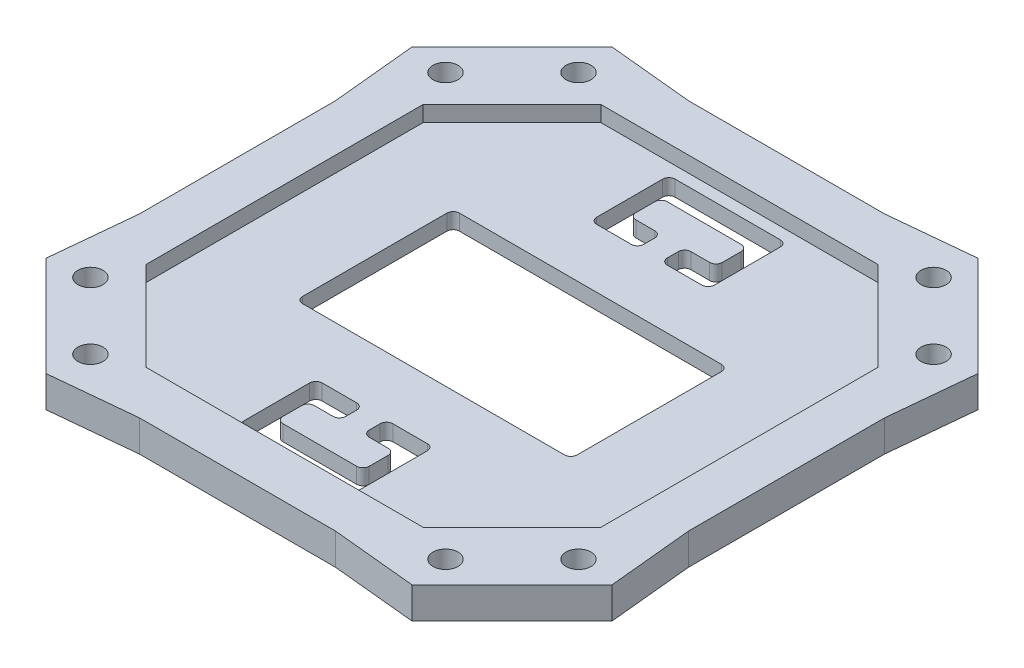
from build123d import *

# Parameters (mm, degrees)
BOSS_EXTRUDE1_DEPTH = 4
SKETCH2_R           = 1.6
CUT_EXTRUDE1_DEPTH  = 5
CUT_EXTRUDE2_DEPTH  = 2
CUT_EXTRUDE3_DEPTH  = 3


with BuildPart() as part:
    # Sketch1 → Boss-Extrude1 (new body)
    with BuildSketch(Plane(origin=(0, 0, 0), x_dir=(1, 0, 0), z_dir=(0, 1, 0))):
        Polygon((-12.5, 0), (12.5, 0), (23.338026386, 1.062677778), (36.065948447, -11.665244283), (35.003270669, -22.503270669), (35.003270669, -47.503270669), (36.065948447, -58.341297055), (23.338026386, -71.069219116), (12.5, -70.006541338), (-12.5, -70.006541338), (-23.338026386, -71.069219116), (-36.065948447, -58.341297055), (-35.003270669, -47.503270669), (-35.003270669, -22.503270669), (-36.065948447, -11.665244283), (-23.338026386, 1.062677778), align=None)
    extrude(amount=BOSS_EXTRUDE1_DEPTH)

    # Sketch2 → Cut-Extrude1 (cut, through all)
    with BuildSketch(Plane(origin=(0, 4, 0), x_dir=(1, 0, 0), z_dir=(0, 1, 0))):
        with Locations((22.63, -3.893270669)):
            Circle(SKETCH2_R)
        with Locations((31.11, -12.373270669)):
            Circle(SKETCH2_R)
        with Locations((-31.11, -12.373270669)):
            Circle(SKETCH2_R)
        with Locations((-22.63, -3.893270669)):
            Circle(SKETCH2_R)
        with Locations((31.11, -57.633270669)):
            Circle(SKETCH2_R)
        with Locations((22.63, -66.113270669)):
            Circle(SKETCH2_R)
        with Locations((-22.63, -66.113270669)):
            Circle(SKETCH2_R)
        with Locations((-31.11, -57.633270669)):
            Circle(SKETCH2_R)
    extrude(amount=-CUT_EXTRUDE1_DEPTH, mode=Mode.SUBTRACT)

    # Sketch3 → Cut-Extrude2 (cut)
    with BuildSketch(Plane(origin=(0, 4, 0), x_dir=(1, 0, 0), z_dir=(0, 1, 0))):
        Polygon((-17.672782103, -6), (17.672782103, -6), (29.003270669, -17.330488566), (29.003270669, -52.676052772), (17.672782103, -64.006541338), (-17.672782103, -64.006541338), (-29.003270669, -52.676052772), (-29.003270669, -17.330488566), align=None)
    extrude(amount=-CUT_EXTRUDE2_DEPTH, mode=Mode.SUBTRACT)

    # Sketch4 → Cut-Extrude3 (cut, through all)
    with BuildSketch(Plane(origin=(0, 2, 0), x_dir=(1, 0, 0), z_dir=(0, 1, 0))):
        with BuildLine():
            Line((-16.7, -45.003270669), (16.7, -45.003270669))
            ThreePointArc((16.7, -45.003270669), (17.265685425, -44.768956094), (17.5, -44.203270669))
            Line((17.5, -44.203270669), (17.5, -25.803270669))
            ThreePointArc((17.5, -25.803270669), (17.265685425, -25.237585244), (16.7, -25.003270669))
            Line((16.7, -25.003270669), (-16.7, -25.003270669))
            ThreePointArc((-16.7, -25.003270669), (-17.265685425, -25.237585244), (-17.5, -25.803270669))
            Line((-17.5, -25.803270669), (-17.5, -44.203270669))
            ThreePointArc((-17.5, -44.203270669), (-17.265685425, -44.768956094), (-16.7, -45.003270669))
        make_face()
        with BuildLine():
            Line((-1.5, -16.703270669), (-1.5, -15.303270669))
            ThreePointArc((-1.5, -15.303270669), (-1.734314575, -14.737585244), (-2.3, -14.503270669))
            Line((-2.3, -14.503270669), (-4.7, -14.503270669))
            ThreePointArc((-4.7, -14.503270669), (-5.265685425, -14.268956094), (-5.5, -13.703270669))
            Line((-5.5, -13.703270669), (-5.5, -11.303270669))
            ThreePointArc((-5.5, -11.303270669), (-5.265685425, -10.737585244), (-4.7, -10.503270669))
            Line((-4.7, -10.503270669), (4.7, -10.503270669))
            ThreePointArc((4.7, -10.503270669), (5.265685425, -10.737585244), (5.5, -11.303270669))
            Line((5.5, -11.303270669), (5.5, -13.703270669))
            ThreePointArc((5.5, -13.703270669), (5.265685425, -14.268956094), (4.7, -14.503270669))
            Line((4.7, -14.503270669), (2.3, -14.503270669))
            ThreePointArc((2.3, -14.503270669), (1.734314575, -14.737585244), (1.5, -15.303270669))
            Line((1.5, -15.303270669), (1.5, -16.703270669))
            ThreePointArc((1.5, -16.703270669), (1.734314575, -17.268956094), (2.3, -17.503270669))
            Line((2.3, -17.503270669), (6.7, -17.503270669))
            ThreePointArc((6.7, -17.503270669), (7.265685425, -17.268956094), (7.5, -16.703270669))
            Line((7.5, -16.703270669), (7.5, -8.303270669))
            ThreePointArc((7.5, -8.303270669), (7.265685425, -7.737585244), (6.7, -7.503270669))
            Line((6.7, -7.503270669), (-6.7, -7.503270669))
            ThreePointArc((-6.7, -7.503270669), (-7.265685425, -7.737585244), (-7.5, -8.303270669))
            Line((-7.5, -8.303270669), (-7.5, -16.703270669))
            ThreePointArc((-7.5, -16.703270669), (-7.265685425, -17.268956094), (-6.7, -17.503270669))
            Line((-6.7, -17.503270669), (-2.3, -17.503270669))
            ThreePointArc((-2.3, -17.503270669), (-1.734314575, -17.268956094), (-1.5, -16.703270669))
        make_face()
        with BuildLine():
            Line((-5.5, -56.303270669), (-5.5, -58.703270669))
            ThreePointArc((-5.5, -58.703270669), (-5.265685425, -59.268956094), (-4.7, -59.503270669))
            Line((-4.7, -59.503270669), (4.7, -59.503270669))
            ThreePointArc((4.7, -59.503270669), (5.265685425, -59.268956094), (5.5, -58.703270669))
            Line((5.5, -58.703270669), (5.5, -56.303270669))
            ThreePointArc((5.5, -56.303270669), (5.265685425, -55.737585244), (4.7, -55.503270669))
            Line((4.7, -55.503270669), (2.3, -55.503270669))
            ThreePointArc((2.3, -55.503270669), (1.734314575, -55.268956094), (1.5, -54.703270669))
            Line((1.5, -54.703270669), (1.5, -53.303270669))
            ThreePointArc((1.5, -53.303270669), (1.734314575, -52.737585244), (2.3, -52.503270669))
            Line((2.3, -52.503270669), (6.7, -52.503270669))
            ThreePointArc((6.7, -52.503270669), (7.265685425, -52.737585244), (7.5, -53.303270669))
            Line((7.5, -53.303270669), (7.5, -61.703270669))
            ThreePointArc((7.5, -61.703270669), (7.265685425, -62.268956094), (6.7, -62.503270669))
            Line((6.7, -62.503270669), (-6.7, -62.503270669))
            ThreePointArc((-6.7, -62.503270669), (-7.265685425, -62.268956094), (-7.5, -61.703270669))
            Line((-7.5, -61.703270669), (-7.5, -53.303270669))
            ThreePointArc((-7.5, -53.303270669), (-7.265685425, -52.737585244), (-6.7, -52.503270669))
            Line((-6.7, -52.503270669), (-2.3, -52.503270669))
            ThreePointArc((-2.3, -52.503270669), (-1.734314575, -52.737585244), (-1.5, -53.303270669))
            Line((-1.5, -53.303270669), (-1.5, -54.703270669))
            ThreePointArc((-1.5, -54.703270669), (-1.734314575, -55.268956094), (-2.3, -55.503270669))
            Line((-2.3, -55.503270669), (-4.7, -55.503270669))
            ThreePointArc((-4.7, -55.503270669), (-5.265685425, -55.737585244), (-5.5, -56.303270669))
        make_face()
    extrude(amount=-CUT_EXTRUDE3_DEPTH, mode=Mode.SUBTRACT)


solid = part.part
